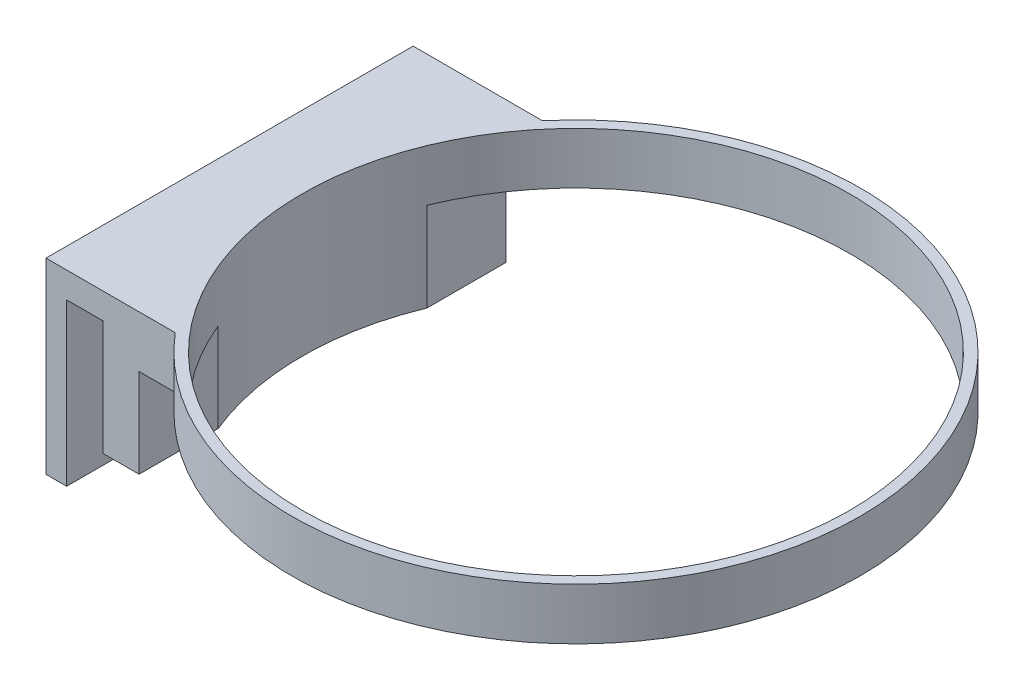
from build123d import *

# Parameters (mm, degrees)
SKETCH1_R           = 53
BOSS_EXTRUDE1_DEPTH = 10
BOSS_EXTRUDE2_DEPTH = 71.021124
SKETCH4_R           = 53
CUT_EXTRUDE1_DEPTH  = 27.217084


with BuildPart() as part:
    # Sketch1 → Boss-Extrude1 (new body)
    with BuildSketch(Plane(origin=(0, 0, 0), x_dir=(1, 0, 0), z_dir=(0, 1, 0))):
        with BuildLine():
            Line((-42, 35.510561809), (-56, 35.510561809))
            Line((-56, 35.510561809), (-56, -35.510561809))
            Line((-56, -35.510561809), (-42, -35.510561809))
            ThreePointArc((-42, -35.510561809), (55, 0), (-42, 35.510561809))
        make_face()
        Circle(SKETCH1_R, mode=Mode.SUBTRACT)
    extrude(amount=BOSS_EXTRUDE1_DEPTH)

    # Sketch3 → Boss-Extrude2 (add)
    with BuildSketch(Plane(origin=(0, 0, -35.510561809), x_dir=(-1, 0, 0), z_dir=(0, 0, -1))):
        Polygon((49, 0), (49, -17.217083866), (56, -17.217083866), (56, 5), (63, 5), (63, -26.22903032), (67, -26.22903032), (67, 10), (49, 10), align=None)
    extrude(amount=-BOSS_EXTRUDE2_DEPTH)

    # Sketch4 → Cut-Extrude1 (cut)
    with BuildSketch(Plane(origin=(0, 10, 0), x_dir=(1, 0, 0), z_dir=(0, 1, 0))):
        Circle(SKETCH4_R)
    extrude(amount=-CUT_EXTRUDE1_DEPTH, mode=Mode.SUBTRACT)


solid = part.part
